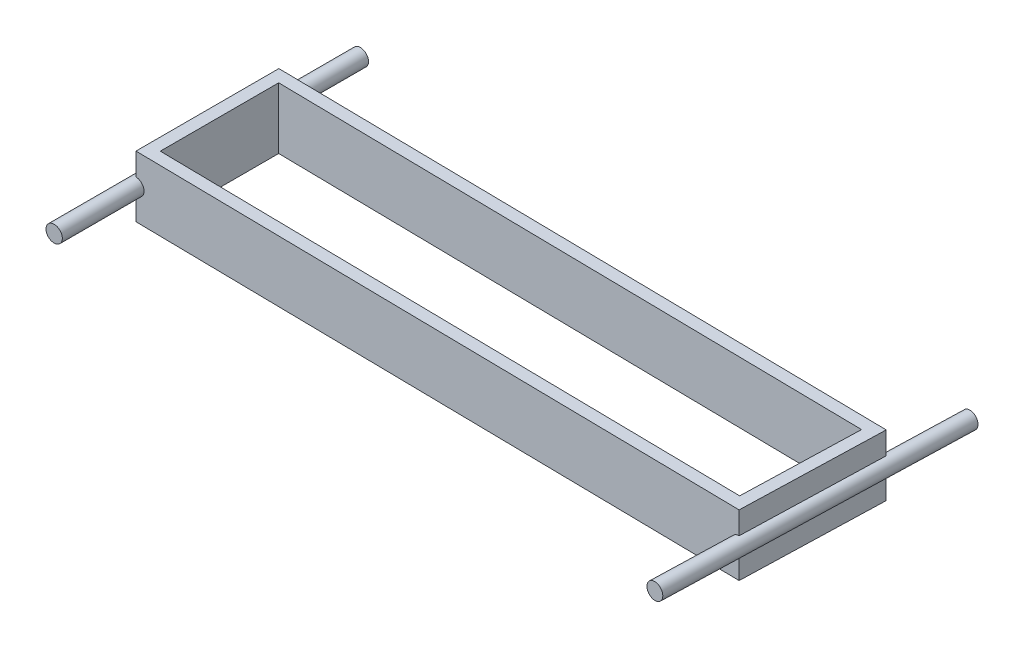
from build123d import *

# Parameters (mm, degrees)
BOSS_EXTRUDE1_DEPTH = 38.1
SKETCH2_R           = 5.08
BOSS_EXTRUDE2_DEPTH = 95.25


with BuildPart() as part:
    # Sketch1 → Boss-Extrude1 (new body)
    with BuildSketch(Plane(origin=(0, 0, 0), x_dir=(1, 0, 0), z_dir=(0, 1, 0))):
        Polygon((-323.578651022, -44.335687139), (57.378484067, -50.050687139), (60.045184013, 38.809307861), (-323.578651022, 44.564312861), align=None)
        Polygon((-315.958651022, -36.829142605), (49.987084067, -42.318946269), (52.196584013, 31.306192713), (-315.958651022, 36.829142605), align=None, mode=Mode.SUBTRACT)
    extrude(amount=-BOSS_EXTRUDE1_DEPTH)

    # Sketch2 → Boss-Extrude2 (add, symmetric)
    with BuildSketch(Plane.XY):
        with Locations((-323.578651022, -19.05)):
            Circle(SKETCH2_R)
    boss_extrude2 = extrude(amount=BOSS_EXTRUDE2_DEPTH, both=True)

    # Mirror1: Boss-Extrude2 across plane
    add(boss_extrude2.mirror(Plane(origin=(-132.362317794, 0, -1.985658166), x_dir=(-0.015, 0, 0.999887494), z_dir=(0.999887494, 0, 0.015))))


solid = part.part
